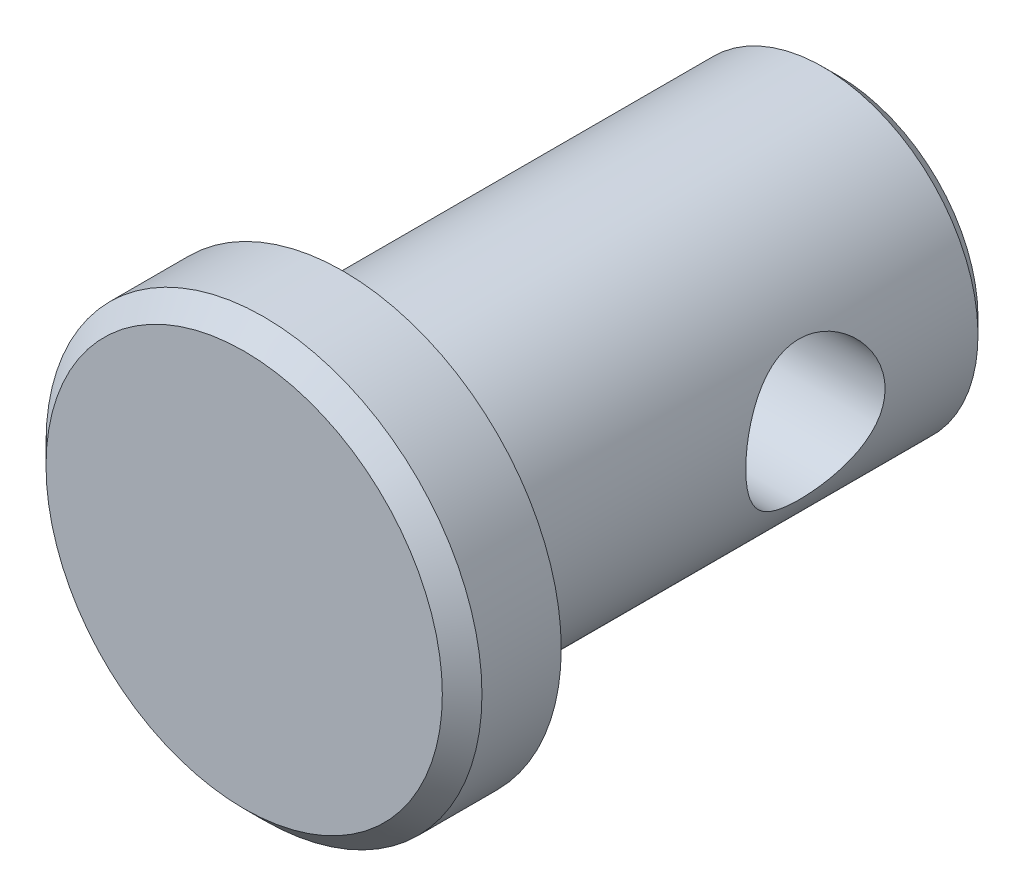
from build123d import *

# Parameters (mm, degrees)
SKETCH11_R              = 1.7859375
CUT_EXTRUDE1_DEPTH      = 6.588
CUT_EXTRUDE1_DEPTH_BACK = 6.588


with BuildPart() as part:
    # Sketch10 → Revolve1 (revolve)
    with BuildSketch(Plane(origin=(0, 0, 0), x_dir=(0, 0, -1), z_dir=(1, 0, 0))):
        Polygon((6.35, 3.571875), (6.35, 0), (-8.89, 0), (-8.89, 5.08), (-8.382, 5.588), (-6.35, 5.588), (-6.35, 3.96875), (5.953125, 3.96875), align=None)
    revolve(axis=Axis((0, 0, 6.35), (0, 0, -1)))

    # Sketch11 → Cut-Extrude1 (cut, two sides)
    with BuildSketch(Plane(origin=(0, 0, 0), x_dir=(0, 0, -1), z_dir=(1, 0, 0))) as cut_extrude1_sk:
        with Locations((1.7859375, 0)):
            Circle(SKETCH11_R)
    extrude(amount=CUT_EXTRUDE1_DEPTH, mode=Mode.SUBTRACT)
    extrude(cut_extrude1_sk.sketch, amount=-CUT_EXTRUDE1_DEPTH_BACK, mode=Mode.SUBTRACT)


solid = part.part
